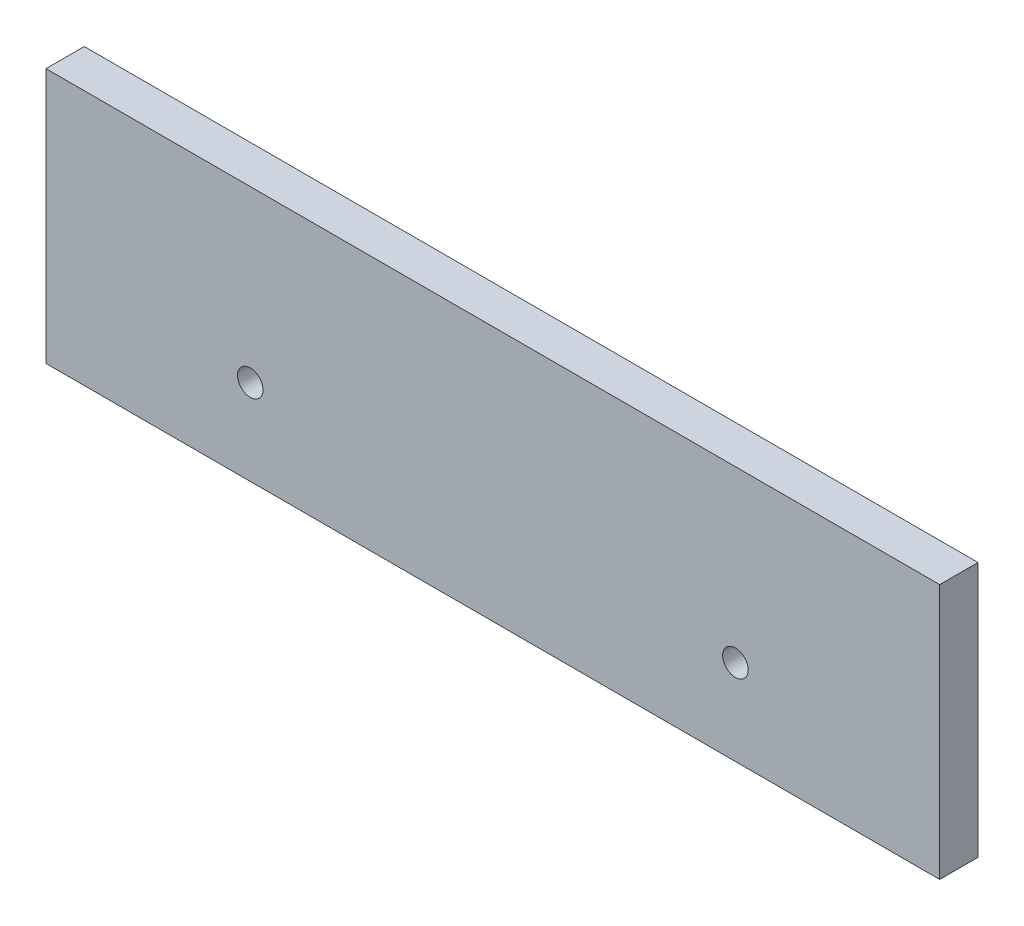
from build123d import *

# Parameters (mm, degrees)
SKETCH2_W           = 350
SKETCH2_H           = 100
SKETCH2_R           = 5
BOSS_EXTRUDE1_DEPTH = 15


with BuildPart() as part:
    # Sketch2 → Boss-Extrude1 (new body)
    with BuildSketch(Plane(origin=(0, 0, 24.311850572), x_dir=(-1, 0, 0), z_dir=(0, 0, -1))):
        with Locations((296.149822386, 62.240526096)):
            Rectangle(SKETCH2_W, SKETCH2_H)
        with Locations((201.149822386, 45.740526096)):
            Circle(SKETCH2_R, mode=Mode.SUBTRACT)
        with Locations((391.149822386, 45.740526096)):
            Circle(SKETCH2_R, mode=Mode.SUBTRACT)
    extrude(amount=-BOSS_EXTRUDE1_DEPTH)


solid = part.part
